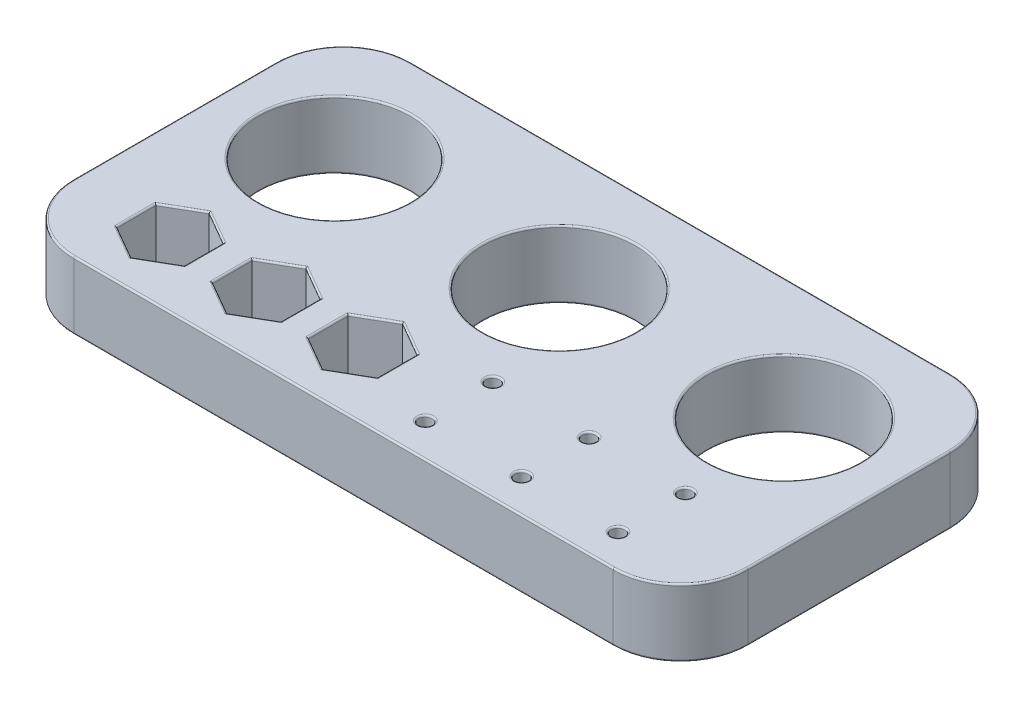
from build123d import *

# Parameters (mm, degrees)
SKETCH1_W        = 127
SKETCH1_H        = 63.5
SKETCH1_R        = 14.2875
SKETCH1_R_2      = 14.362499977
SKETCH1_R_3      = 14.437499954
SKETCH1_R_4      = 1.27
TEST_PLATE_DEPTH = 12.7
CORNER_FILLET_R  = 12.7
FACE_SMOOTH_R    = 0.3175


with BuildPart() as part:
    # Sketch1 → Test Plate (new body)
    with BuildSketch(Plane(origin=(0, 0, 0), x_dir=(1, 0, 0), z_dir=(0, 1, 0))):
        Rectangle(SKETCH1_W, SKETCH1_H)
        with Locations((-42.333333333, 8.89)):
            Circle(SKETCH1_R, mode=Mode.SUBTRACT)
        with Locations((0, 8.89)):
            Circle(SKETCH1_R_2, mode=Mode.SUBTRACT)
        with Locations((42.333333333, 8.89)):
            Circle(SKETCH1_R_3, mode=Mode.SUBTRACT)
        with Locations((9.071428571, -12.7)):
            Circle(SKETCH1_R_4, mode=Mode.SUBTRACT)
        with Locations((27.214285714, -12.7)):
            Circle(SKETCH1_R_4, mode=Mode.SUBTRACT)
        with Locations((45.357142857, -12.7)):
            Circle(SKETCH1_R_4, mode=Mode.SUBTRACT)
        with Locations((45.357142857, -25.4)):
            Circle(SKETCH1_R_4, mode=Mode.SUBTRACT)
        with Locations((27.214285714, -25.4)):
            Circle(SKETCH1_R_4, mode=Mode.SUBTRACT)
        with Locations((9.071428571, -25.4)):
            Circle(SKETCH1_R_4, mode=Mode.SUBTRACT)
        Polygon((-39.007142857, -15.383825791), (-45.357142857, -11.717651581), (-51.707142857, -15.383825791), (-51.707142857, -22.716174209), (-45.357142857, -26.382348419), (-39.007142857, -22.716174209), align=None, mode=Mode.SUBTRACT)
        Polygon((-20.789285737, -22.759475466), (-20.789285737, -15.340524534), (-27.214285714, -11.631049067), (-33.639285691, -15.340524534), (-33.639285691, -22.759475466), (-27.214285714, -26.468950933), align=None, mode=Mode.SUBTRACT)
        Polygon((-2.571428617, -22.802776723), (-2.571428617, -15.297223277), (-9.071428571, -11.544446554), (-15.571428525, -15.297223277), (-15.571428525, -22.802776723), (-9.071428571, -26.555553446), align=None, mode=Mode.SUBTRACT)
    extrude(amount=TEST_PLATE_DEPTH)

    # Corner Fillet
    corner_fillet_edges = [part.edges().sort_by_distance(p)[0] for p in [
        (63.5, 6.35, 31.75),
        (-63.5, 6.35, 31.75),
        (-63.5, 6.35, -31.75),
        (63.5, 6.35, -31.75),
    ]]
    fillet(corner_fillet_edges, radius=CORNER_FILLET_R)

    # Face Smooth
    face_smooth_edges = [part.edges().sort_by_distance(p)[0] for p in [
        (-63.5, 0, 0),
        (-63.5, 12.7, 0),
        (63.5, 0, 0),
        (0, 0, 31.75),
        (0, 0, -31.75),
        (-59.780256121, 0, 28.030256121),
        (59.780256121, 0, 28.030256121),
        (59.780256121, 0, -28.030256121),
        (-59.780256121, 0, -28.030256121),
        (0, 12.7, -31.75),
        (63.5, 12.7, 0),
        (0, 12.7, 31.75),
        (-59.780256121, 12.7, 28.030256121),
        (-14.362499977, 0, -8.89),
        (59.780256121, 12.7, 28.030256121),
        (59.780256121, 12.7, -28.030256121),
        (-59.780256121, 12.7, -28.030256121),
        (-14.362499977, 12.7, -8.89),
        (-56.620833333, 0, -8.89),
        (-56.620833333, 12.7, -8.89),
        (27.895833379, 0, -8.89),
        (27.895833379, 12.7, -8.89),
        (-39.007142857, 0, 19.05),
        (-42.182142857, 0, 13.550738686),
        (-48.532142857, 0, 13.550738686),
        (-51.707142857, 0, 19.05),
        (-48.532142857, 0, 24.549261314),
        (-42.182142857, 0, 24.549261314),
        (-39.007142857, 12.7, 19.05),
        (-42.182142857, 12.7, 13.550738686),
        (-48.532142857, 12.7, 13.550738686),
        (-51.707142857, 12.7, 19.05),
        (-48.532142857, 12.7, 24.549261314),
        (-42.182142857, 12.7, 24.549261314),
        (-24.001785726, 0, 24.614213199),
        (-20.789285737, 0, 19.05),
        (-24.001785726, 0, 13.485786801),
        (-30.426785703, 0, 13.485786801),
        (-33.639285691, 0, 19.05),
        (-30.426785703, 0, 24.614213199),
        (-24.001785726, 12.7, 24.614213199),
        (-20.789285737, 12.7, 19.05),
        (-24.001785726, 12.7, 13.485786801),
        (-30.426785703, 12.7, 13.485786801),
        (-33.639285691, 12.7, 19.05),
        (-30.426785703, 12.7, 24.614213199),
        (-5.821428594, 0, 24.679165085),
        (-2.571428617, 0, 19.05),
        (-5.821428594, 0, 13.420834915),
        (-12.321428548, 0, 13.420834915),
        (-15.571428525, 0, 19.05),
        (-12.321428548, 0, 24.679165085),
        (-5.821428594, 12.7, 24.679165085),
        (-2.571428617, 12.7, 19.05),
        (-5.821428594, 12.7, 13.420834915),
        (-12.321428548, 12.7, 13.420834915),
        (-15.571428525, 12.7, 19.05),
        (-12.321428548, 12.7, 24.679165085),
        (7.801428571, 0, 12.7),
        (7.801428571, 12.7, 12.7),
        (25.944285714, 0, 12.7),
        (25.944285714, 12.7, 12.7),
        (44.087142857, 0, 12.7),
        (44.087142857, 12.7, 12.7),
        (44.087142857, 0, 25.4),
        (44.087142857, 12.7, 25.4),
        (25.944285714, 0, 25.4),
        (25.944285714, 12.7, 25.4),
        (7.801428571, 0, 25.4),
        (7.801428571, 12.7, 25.4),
    ]]
    fillet(face_smooth_edges, radius=FACE_SMOOTH_R)


solid = part.part
